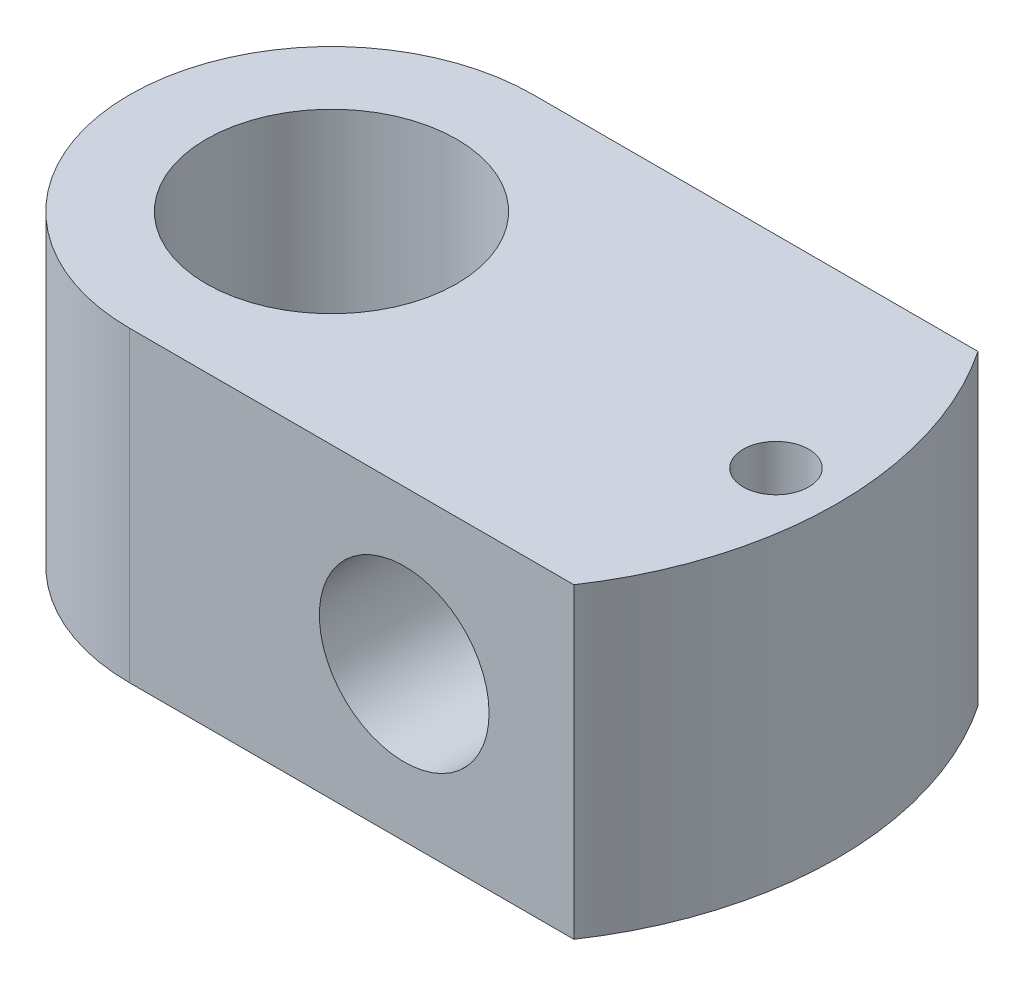
from build123d import *

# Parameters (mm, degrees)
BOSS_EXTRUDE1_DEPTH = 24.13
SKETCH2_R           = 19.685
CUT_EXTRUDE1_DEPTH  = 49.26
SKETCH3_R           = 13.335
CUT_EXTRUDE2_DEPTH  = 64.5
SKETCH4_R           = 5.1435
CUT_EXTRUDE3_DEPTH  = 49.26


with BuildPart() as part:
    # Sketch1 → Boss-Extrude1 (new body, symmetric)
    with BuildSketch(Plane(origin=(0, 0, 0), x_dir=(1, 0, 0), z_dir=(0, 1, 0))):
        with BuildLine():
            Line((0, 31.75), (69.85, 31.75))
            ThreePointArc((69.85, 31.75), (79.502, 0), (69.85, -31.75))
            Line((69.85, -31.75), (0, -31.75))
            ThreePointArc((0, -31.75), (-31.75, 0), (0, 31.75))
        make_face()
    extrude(amount=BOSS_EXTRUDE1_DEPTH, both=True)

    # Sketch2 → Cut-Extrude1 (cut, through all)
    with BuildSketch(Plane(origin=(0, 24.13, 0), x_dir=(1, 0, 0), z_dir=(0, 1, 0))):
        Circle(SKETCH2_R)
    extrude(amount=-CUT_EXTRUDE1_DEPTH, mode=Mode.SUBTRACT)

    # Sketch3 → Cut-Extrude2 (cut, through all)
    with BuildSketch(Plane.XY.offset(31.75)):
        with Locations((43.18, 0)):
            Circle(SKETCH3_R)
    extrude(amount=-CUT_EXTRUDE2_DEPTH, mode=Mode.SUBTRACT)

    # Sketch4 → Cut-Extrude3 (cut, through all)
    with BuildSketch(Plane(origin=(0, 24.13, 0), x_dir=(1, 0, 0), z_dir=(0, 1, 0))):
        with Locations((69.85, 0)):
            Circle(SKETCH4_R)
    extrude(amount=-CUT_EXTRUDE3_DEPTH, mode=Mode.SUBTRACT)


solid = part.part
